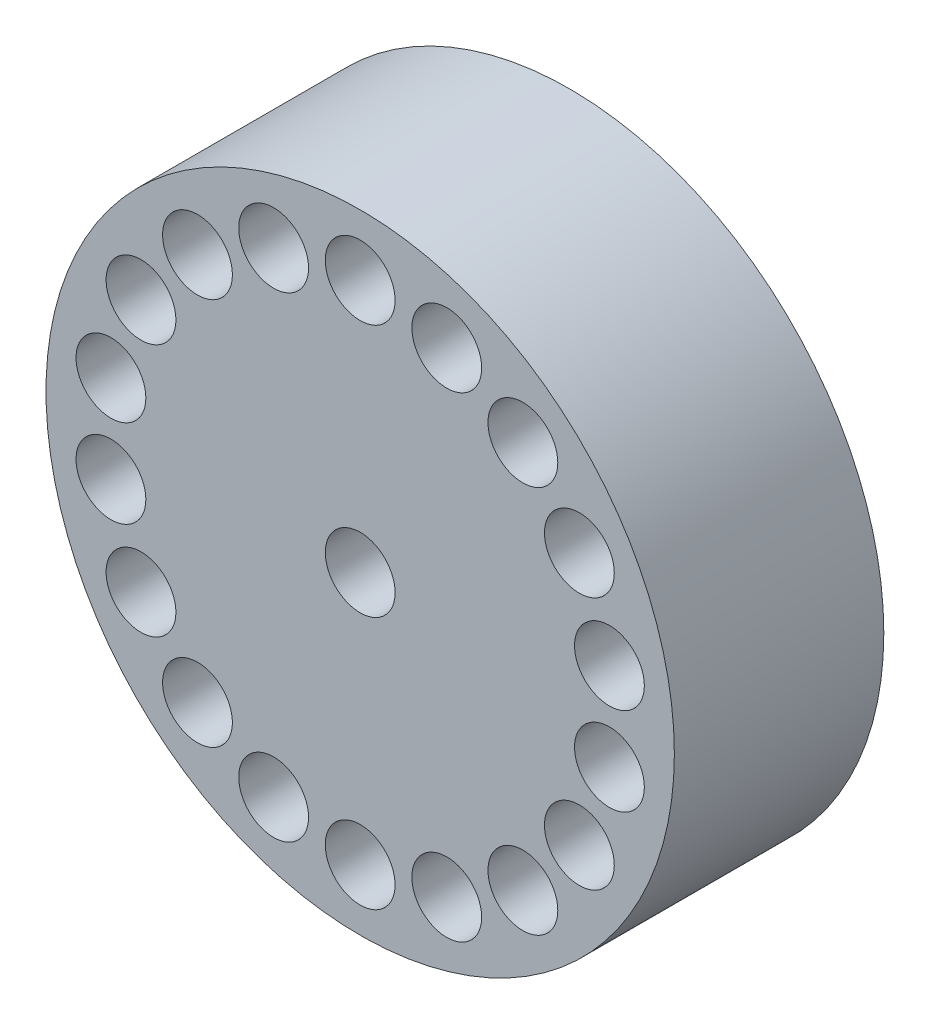
from build123d import *

# Parameters (mm, degrees)
SZKIC1_R                    = 4.5
SZKIC1_R_2                  = 0.5
DODANIE_WYCI_GNI_CIE1_DEPTH = 3
SZKIC2_R                    = 0.5
WYTNIJ_WYCI_GNI_CIE2_DEPTH  = 1


with BuildPart() as part:
    # Szkic1 → Dodanie-wyciągnięcie1 (new body)
    with BuildSketch(Plane.XY):
        Circle(SZKIC1_R)
        Circle(SZKIC1_R_2, mode=Mode.SUBTRACT)
    extrude(amount=DODANIE_WYCI_GNI_CIE1_DEPTH)

    # Szkic2 → Wytnij-wyciągnięcie2 (cut)
    with BuildSketch(Plane.XY.offset(3)):
        with Locations((0, 3.625)):
            Circle(SZKIC2_R)
        with Locations((1.23982302, 3.40638575)):
            Circle(SZKIC2_R)
        with Locations((2.330105085, 2.776911106)):
            Circle(SZKIC2_R)
        with Locations((3.139342089, 1.8125)):
            Circle(SZKIC2_R)
        with Locations((3.569928105, 0.629474644)):
            Circle(SZKIC2_R)
        with Locations((3.569928105, -0.629474644)):
            Circle(SZKIC2_R)
        with Locations((3.139342089, -1.8125)):
            Circle(SZKIC2_R)
        with Locations((2.330105085, -2.776911106)):
            Circle(SZKIC2_R)
        with Locations((1.23982302, -3.40638575)):
            Circle(SZKIC2_R)
        with Locations((0, -3.625)):
            Circle(SZKIC2_R)
        with Locations((-1.23982302, -3.40638575)):
            Circle(SZKIC2_R)
        with Locations((-2.330105085, -2.776911106)):
            Circle(SZKIC2_R)
        with Locations((-3.139342089, -1.8125)):
            Circle(SZKIC2_R)
        with Locations((-3.569928105, -0.629474644)):
            Circle(SZKIC2_R)
        with Locations((-3.569928105, 0.629474644)):
            Circle(SZKIC2_R)
        with Locations((-3.139342089, 1.8125)):
            Circle(SZKIC2_R)
        with Locations((-2.330105085, 2.776911106)):
            Circle(SZKIC2_R)
        with Locations((-1.23982302, 3.40638575)):
            Circle(SZKIC2_R)
    extrude(amount=-WYTNIJ_WYCI_GNI_CIE2_DEPTH, mode=Mode.SUBTRACT)


solid = part.part
